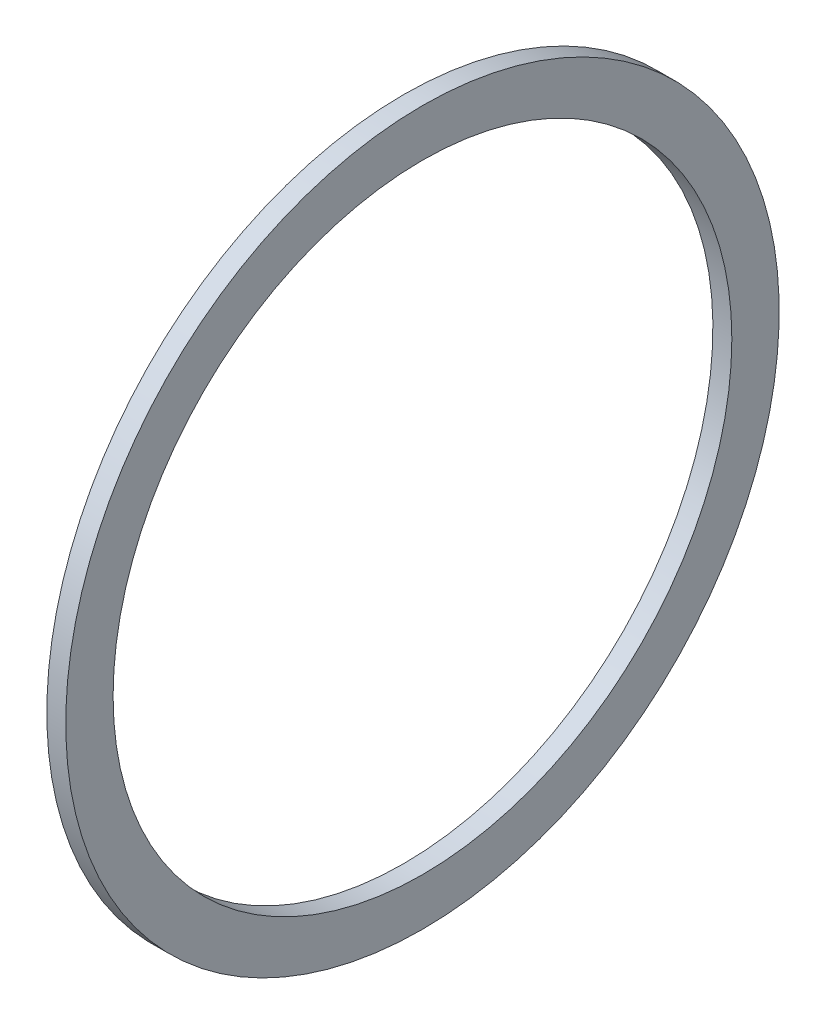
from build123d import *

# Parameters (mm, degrees)
SKIZZE1_W                        = 3
SKIZZE1_H                        = 52.95
F_4_7_4_7_DURCHMESSER_BOHRUNG1_D = 4.7
SKIZZE5_RX                       = 25
SKIZZE5_RY                       = 10
SCHNITT_LINEAR_AUSTRAGEN1_DEPTH  = 3
KREISMUSTER1_COUNT               = 4
CUT_EXTRUDE1_REACH               = 5
SKETCH1_R                        = 49


with BuildPart() as part:
    # Skizze1 → Rotation1 (revolve)
    with BuildSketch(Plane.XY):
        with Locations((-39.553372853, 39.775)):
            Rectangle(SKIZZE1_W, SKIZZE1_H)
    revolve(axis=Axis((-17.6629112, 9.75, 0), (-1, 0, 0)))

    # Ø4.7 (4.7) Durchmesser Bohrung1 (through all)
    with Locations(Plane(origin=(-41.053372853, 11.968723204, 19.868936148), x_dir=(0, 0, 1), z_dir=(-1, 0, 0))):
        with Locations((-13.504975118, -8.582684234), (-26.232897179, -8.582684234), (-26.232897179, 4.145237827), (-13.504975118, 4.145237827)):
            Hole(F_4_7_4_7_DURCHMESSER_BOHRUNG1_D / 2)

    # Skizze5 → Schnitt-Linear austragen1 (cut)
    with BuildSketch(Plane(origin=(-38.053372853, 0, 0), x_dir=(0, 0, -1), z_dir=(1, 0, 0))):
        with Locations(Location((-23.027329597, 32.684515508), (0, 0, 45.090609512))):
            Ellipse(SKIZZE5_RX, SKIZZE5_RY)
    schnitt_linear_austragen1 = extrude(amount=-SCHNITT_LINEAR_AUSTRAGEN1_DEPTH, mode=Mode.SUBTRACT)

    # Kreismuster1: Schnitt-Linear austragen1 ×4 about axis
    kreismuster1_axis = Axis((0, 9.75, 0), (-1, 0, 0))
    for i in range(1, KREISMUSTER1_COUNT):
        add(schnitt_linear_austragen1.rotate(kreismuster1_axis, i * 360 / KREISMUSTER1_COUNT), mode=Mode.SUBTRACT)

    # Sketch1 → Cut-Extrude1 (cut, up to next)
    with BuildSketch(Plane.ZY.offset(41.053372853), mode=Mode.PRIVATE) as cut_extrude1_sk1:
        with Locations((0, 9.75)):
            Circle(SKETCH1_R)
    cut_extrude1_tool1 = extrude(cut_extrude1_sk1.sketch, amount=-CUT_EXTRUDE1_REACH, mode=Mode.PRIVATE) & part.part
    add(cut_extrude1_tool1.solids().sort_by_distance((-41.053373, 9.75, 0))[0], mode=Mode.SUBTRACT)


solid = part.part
